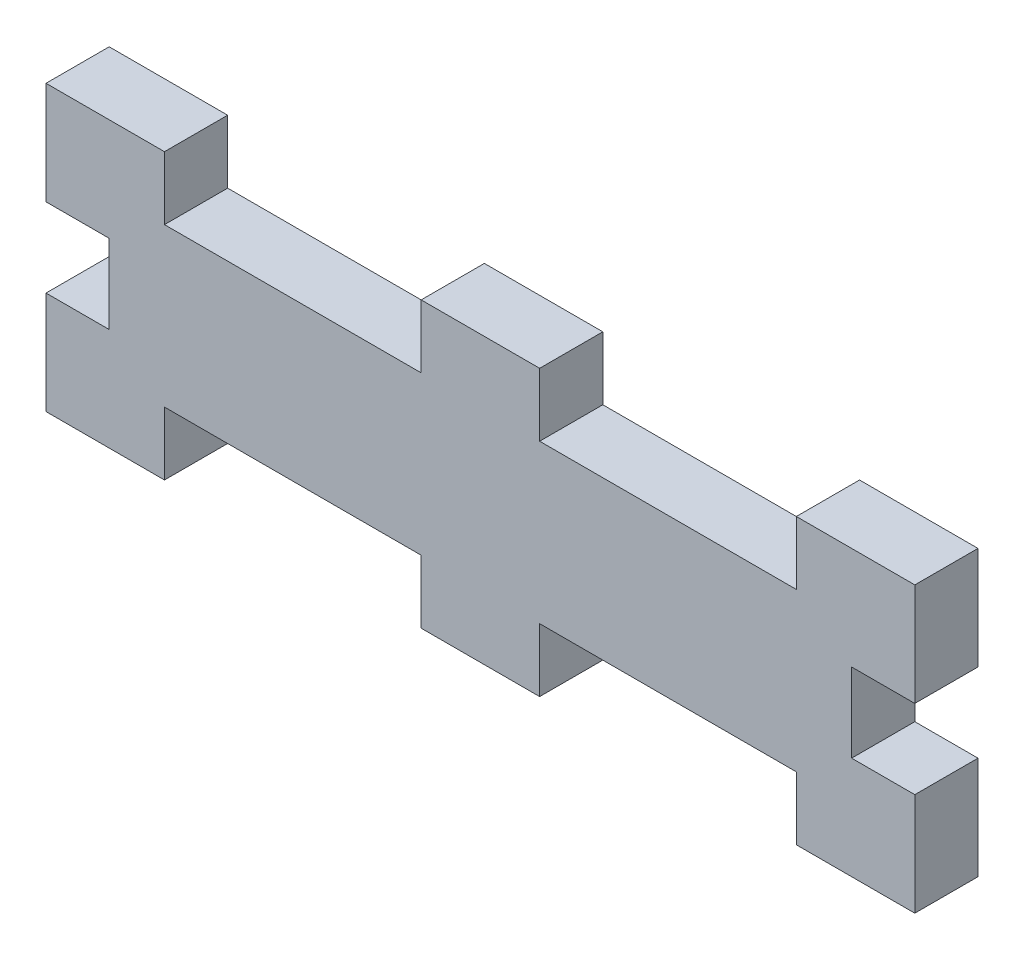
from build123d import *

# Parameters (mm, degrees)
SKETCH1_W           = 69.85
SKETCH1_H           = 12.7
BOSS_EXTRUDE1_DEPTH = 5.08
SKETCH2_W           = 9.525
SKETCH2_H           = 5.08
BOSS_EXTRUDE2_DEPTH = 5.08
SKETCH3_W           = 5.08
SKETCH3_H           = 6.35
CUT_EXTRUDE1_DEPTH  = 5.08


with BuildPart() as part:
    # Sketch1 → Boss-Extrude1 (new body)
    with BuildSketch(Plane.XY):
        Rectangle(SKETCH1_W, SKETCH1_H)
    extrude(amount=BOSS_EXTRUDE1_DEPTH)

    # Sketch2 → Boss-Extrude2 (add)
    with BuildSketch(Plane.XY.offset(5.08)):
        with Locations((-30.1625, 8.89)):
            Rectangle(SKETCH2_W, SKETCH2_H)
        with Locations((30.1625, 8.89)):
            Rectangle(SKETCH2_W, SKETCH2_H)
        with Locations((0, 8.89)):
            Rectangle(SKETCH2_W, SKETCH2_H)
    boss_extrude2 = extrude(amount=-BOSS_EXTRUDE2_DEPTH)

    # Mirror1: Boss-Extrude2 across plane
    add(boss_extrude2.mirror(Plane.ZX))

    # Sketch3 → Cut-Extrude1 (cut)
    with BuildSketch(Plane.XY.offset(5.08)):
        with Locations((-32.385, 0)):
            Rectangle(SKETCH3_W, SKETCH3_H)
        with Locations((32.385, 0)):
            Rectangle(SKETCH3_W, SKETCH3_H)
    extrude(amount=-CUT_EXTRUDE1_DEPTH, mode=Mode.SUBTRACT)


solid = part.part
